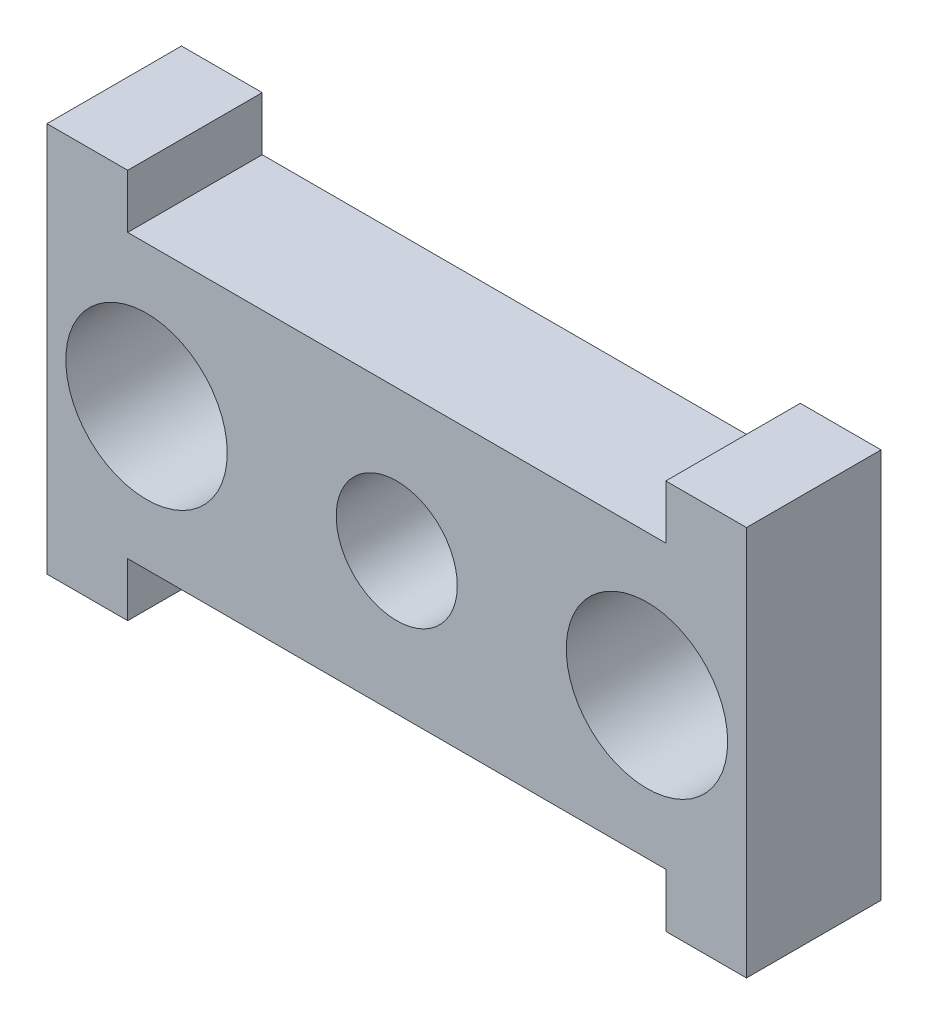
from build123d import *

# Parameters (mm, degrees)
SKETCH1_R           = 3
SKETCH1_R_2         = 2.25
BOSS_EXTRUDE1_DEPTH = 5


with BuildPart() as part:
    # Sketch1 → Boss-Extrude1 (new body)
    with BuildSketch(Plane.XY):
        Polygon((-13, 7.25), (-13, -7.25), (-10, -7.25), (-10, -5.25), (10, -5.25), (10, -7.25), (13, -7.25), (13, 7.25), (10, 7.25), (10, 5.25), (-10, 5.25), (-10, 7.25), align=None)
        with Locations((-9.3, 0)):
            Circle(SKETCH1_R, mode=Mode.SUBTRACT)
        Circle(SKETCH1_R_2, mode=Mode.SUBTRACT)
        with Locations((9.3, 0)):
            Circle(SKETCH1_R, mode=Mode.SUBTRACT)
    extrude(amount=BOSS_EXTRUDE1_DEPTH)


solid = part.part
